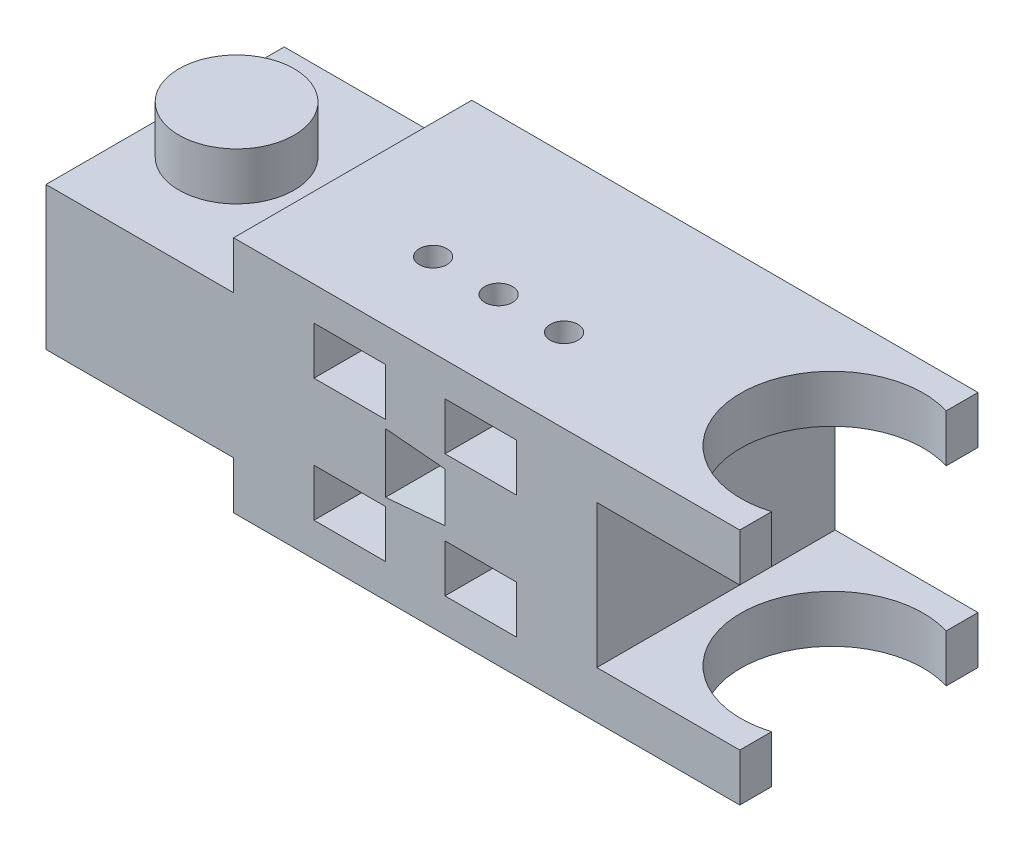
from build123d import *

# Parameters (mm, degrees)
BOSS_EXTRUDE1_DEPTH = 20
SKETCH2_R           = 4.835
BOSS_EXTRUDE2_DEPTH = 4
CUT_EXTRUDE1_REACH  = 64.738
SKETCH3_R           = 7.665
CUT_EXTRUDE2_DEPTH  = 10
SKETCH5_W           = 6
SKETCH5_H           = 4
CUT_EXTRUDE3_DEPTH  = 10
CUT_EXTRUDE4_REACH  = 64.738
SKETCH6_R           = 1.165


with BuildPart() as part:
    # Sketch1 → Boss-Extrude1 (new body)
    with BuildSketch(Plane.XY):
        Polygon((-40.25, -10), (-40.25, -6), (-50, -6), (-56, -6), (-56, 6), (-50, 6), (-40.25, 6), (-40.25, 10), (0, 10), (2.25, 10), (2.25, 6), (0, 6), (-9.75, 6), (-9.75, -6), (0, -6), (2.25, -6), (2.25, -10), (0, -10), align=None)
    extrude(amount=BOSS_EXTRUDE1_DEPTH)

    # Sketch2 → Boss-Extrude2 (add)
    with BuildSketch(Plane.XZ.offset(6)):
        with Locations(Location((-50, 10, 0), (0, 0, 180))):
            Circle(SKETCH2_R)
    boss_extrude2 = extrude(amount=BOSS_EXTRUDE2_DEPTH)

    # Cut-Extrude1: up to this face of the body (flat: up to its plane)
    cut_extrude1_end = Plane(part.part.faces().sort_by_distance((-19, 10, 10))[0])
    # Sketch3 → Cut-Extrude1 (cut, up to the picked face)
    with BuildSketch(Plane.XZ.offset(10), mode=Mode.PRIVATE) as cut_extrude1_sk1:
        with Locations((0, 10)):
            Circle(SKETCH3_R)
    cut_extrude1_tool1 = split(extrude(cut_extrude1_sk1.sketch, amount=-CUT_EXTRUDE1_REACH, mode=Mode.PRIVATE), bisect_by=cut_extrude1_end, keep=Keep.BOTH, mode=Mode.PRIVATE)
    add(cut_extrude1_tool1.solids().sort_by(Axis((0, -10, 10), (0, 1, 0)))[0], mode=Mode.SUBTRACT)

    # Mirror1: Boss-Extrude2 across plane
    add(boss_extrude2.mirror(Plane.ZX))

    # Sketch4 → Cut-Extrude2 (cut)
    with BuildSketch(Plane.XY.offset(20)):
        Polygon((-27.5, 2.5), (-22.5, 2.062556682), (-22.5, -2.062556682), (-27.5, -2.5), align=None)
    extrude(amount=-CUT_EXTRUDE2_DEPTH, mode=Mode.SUBTRACT)

    # Sketch5 → Cut-Extrude3 (cut)
    with BuildSketch(Plane.XY.offset(20)):
        with Locations((-30.5, 5.165)):
            Rectangle(SKETCH5_W, SKETCH5_H)
        with Locations((-19.5, 5.165)):
            Rectangle(SKETCH5_W, SKETCH5_H)
        with Locations((-19.5, -5.165)):
            Rectangle(SKETCH5_W, SKETCH5_H)
        with Locations((-30.5, -5.165)):
            Rectangle(SKETCH5_W, SKETCH5_H)
    extrude(amount=-CUT_EXTRUDE3_DEPTH, mode=Mode.SUBTRACT)

    # Cut-Extrude4: up to this face of the body (flat: up to its plane)
    cut_extrude4_end = Plane(part.part.faces().sort_by_distance((-21.952820108, 10, 10))[0])
    # Sketch6 → Cut-Extrude4 (cut, up to the picked face)
    with BuildSketch(Plane.XZ.offset(10), mode=Mode.PRIVATE) as cut_extrude4_sk1:
        with Locations(Location((-30.5, 13, 0), (0, 0, 270))):
            Circle(SKETCH6_R)
    cut_extrude4_tool1 = split(extrude(cut_extrude4_sk1.sketch, amount=-CUT_EXTRUDE4_REACH, mode=Mode.PRIVATE), bisect_by=cut_extrude4_end, keep=Keep.BOTH, mode=Mode.PRIVATE)
    # Sketch6 → Cut-Extrude4 (cut, up to the picked face)
    with BuildSketch(Plane.XZ.offset(10), mode=Mode.PRIVATE) as cut_extrude4_sk2:
        with Locations((-25, 13)):
            Circle(SKETCH6_R)
    cut_extrude4_tool2 = split(extrude(cut_extrude4_sk2.sketch, amount=-CUT_EXTRUDE4_REACH, mode=Mode.PRIVATE), bisect_by=cut_extrude4_end, keep=Keep.BOTH, mode=Mode.PRIVATE)
    # Sketch6 → Cut-Extrude4 (cut, up to the picked face)
    with BuildSketch(Plane.XZ.offset(10), mode=Mode.PRIVATE) as cut_extrude4_sk3:
        with Locations(Location((-19.5, 13, 0), (0, 0, 90))):
            Circle(SKETCH6_R)
    cut_extrude4_tool3 = split(extrude(cut_extrude4_sk3.sketch, amount=-CUT_EXTRUDE4_REACH, mode=Mode.PRIVATE), bisect_by=cut_extrude4_end, keep=Keep.BOTH, mode=Mode.PRIVATE)
    add(cut_extrude4_tool1.solids().sort_by(Axis((-30.5, -10, 13), (0, 1, 0)))[0], mode=Mode.SUBTRACT)
    add(cut_extrude4_tool2.solids().sort_by(Axis((-25, -10, 13), (0, 1, 0)))[0], mode=Mode.SUBTRACT)
    add(cut_extrude4_tool3.solids().sort_by(Axis((-19.5, -10, 13), (0, 1, 0)))[0], mode=Mode.SUBTRACT)


solid = part.part
